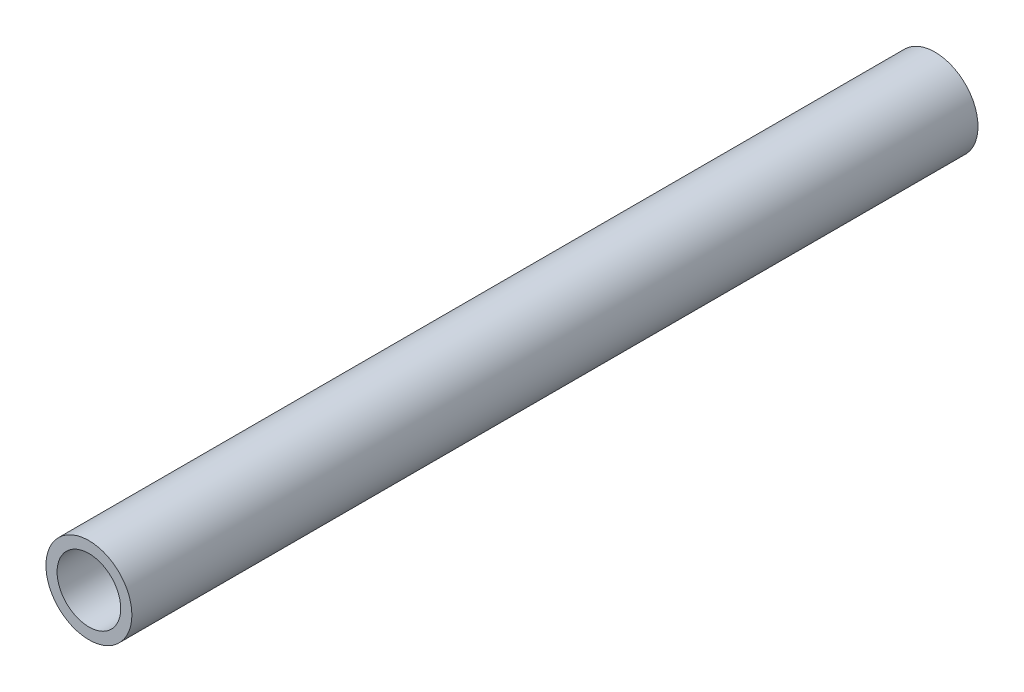
from build123d import *

# Parameters (mm, degrees)
SKETCH1_R           = 10.668
SKETCH1_R_2         = 7.8994
EXTRUDE_THIN1_DEPTH = 105


with BuildPart() as part:
    # Sketch1 → Extrude-Thin1 (new body, symmetric)
    with BuildSketch(Plane.XY):
        Circle(SKETCH1_R)
        Circle(SKETCH1_R_2, mode=Mode.SUBTRACT)
    extrude(amount=EXTRUDE_THIN1_DEPTH, both=True)


solid = part.part
